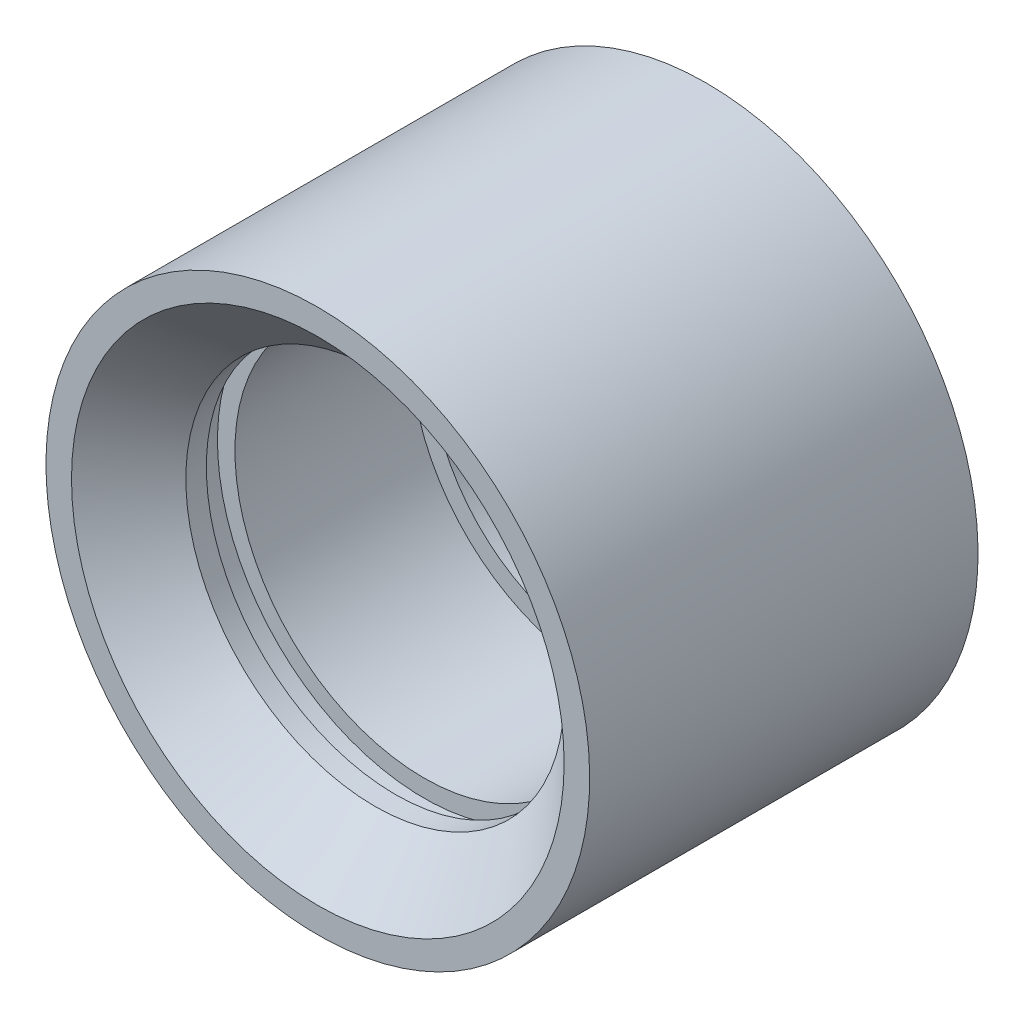
from build123d import *


with BuildPart() as part:
    # Sketch1 → Body (revolve)
    with BuildSketch(Plane(origin=(0, 0, 0), x_dir=(0, 0, -1), z_dir=(1, 0, 0))):
        Polygon((-5.6007, -7.73176), (-7.9375, -10.06856), (-7.9375, -11.1125), (7.9375, -11.1125), (7.9375, -10.06856), (4.81457, -6.94563), (3.5941, -6.94563), (3.5941, -7.73176), (-3.5941, -7.73176), (-3.5941, -8.4455), (-4.7625, -8.4455), (-4.7625, -7.73176), align=None)
    revolve(axis=Axis((0, 0, -7.9375), (0, 0, 1)))


solid = part.part
